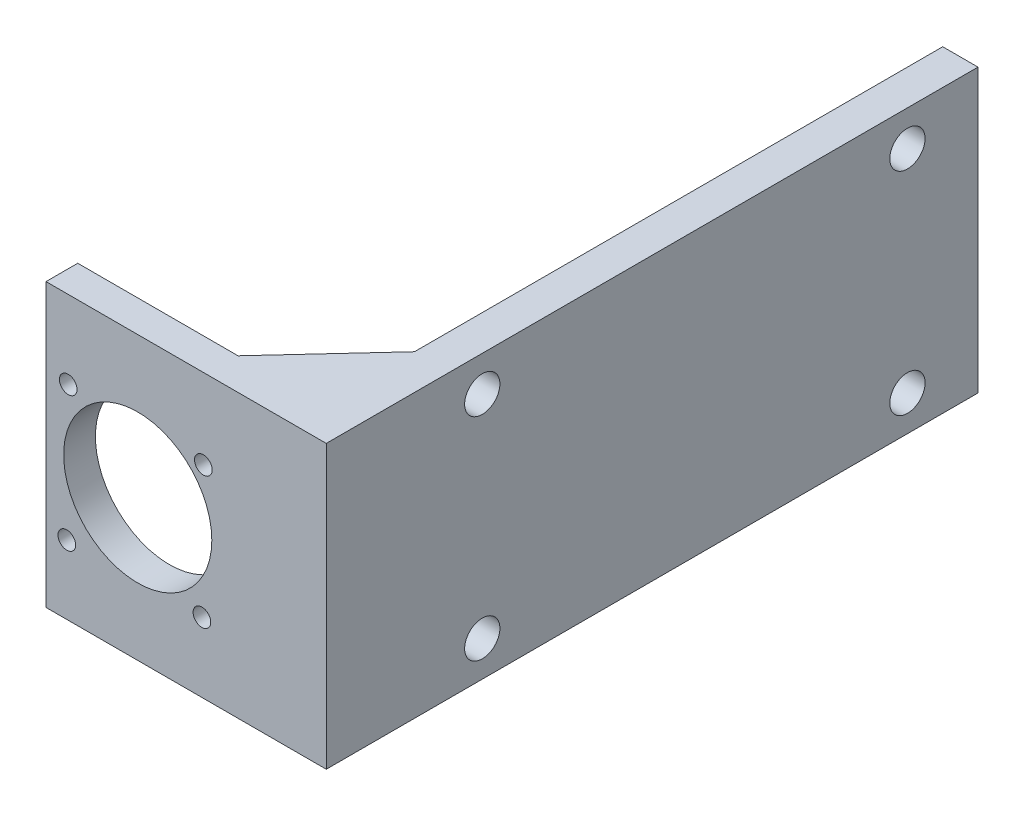
from build123d import *

# Parameters (mm, degrees)
SKETCH1_R           = 10.5
SKETCH1_R_2         = 1.25
BOSS_EXTRUDE1_DEPTH = 4.5
SKETCH2_W           = 5
SKETCH2_H           = 40
BOSS_EXTRUDE2_DEPTH = 87.869807
SKETCH3_R           = 2.5
CUT_EXTRUDE1_DEPTH  = 6
BOSS_EXTRUDE3_DEPTH = 20
SKETCH5_W           = 12
SKETCH5_H           = 34
CUT_EXTRUDE2_DEPTH  = 87.869807
FILLET1_R           = 5


with BuildPart() as part:
    # Sketch1 → Boss-Extrude1 (new body)
    with BuildSketch(Plane.XY):
        Polygon((-26, -6), (0, -6), (13.72, -6), (13.72, 34), (0, 34), (-26, 34), align=None)
        with Locations((-13, 14)):
            Circle(SKETCH1_R, mode=Mode.SUBTRACT)
        with Locations((-3.9, 3.85)):
            Circle(SKETCH1_R_2, mode=Mode.SUBTRACT)
        with Locations((-23.05, 3.75)):
            Circle(SKETCH1_R_2, mode=Mode.SUBTRACT)
        with Locations((-22.85, 22.95)):
            Circle(SKETCH1_R_2, mode=Mode.SUBTRACT)
        with Locations((-3.7, 22.65)):
            Circle(SKETCH1_R_2, mode=Mode.SUBTRACT)
    extrude(amount=BOSS_EXTRUDE1_DEPTH)

    # Sketch2 → Boss-Extrude2 (add)
    with BuildSketch(Plane(origin=(0, 0, 0), x_dir=(-1, 0, 0), z_dir=(0, 0, -1))):
        with Locations((-11.22, 14)):
            Rectangle(SKETCH2_W, SKETCH2_H)
    extrude(amount=BOSS_EXTRUDE2_DEPTH)

    # Sketch3 → Cut-Extrude1 (cut, through all)
    with BuildSketch(Plane.ZY.offset(-8.72)):
        with Locations((-77.869807398, 29)):
            Circle(SKETCH3_R)
        with Locations((-77.869807398, -1)):
            Circle(SKETCH3_R)
        with Locations((-17.609807398, -1)):
            Circle(SKETCH3_R)
        with Locations((-17.609807398, 29)):
            Circle(SKETCH3_R)
    extrude(amount=-CUT_EXTRUDE1_DEPTH, mode=Mode.SUBTRACT)

    # Sketch4 → Boss-Extrude3 (add, symmetric)
    with BuildSketch(Plane(origin=(0, 14, 0), x_dir=(1, 0, 0), z_dir=(0, 1, 0))):
        Polygon((8.72, 13), (-3.28, 0), (8.72, 0), align=None)
    extrude(amount=BOSS_EXTRUDE3_DEPTH, both=True)

    # Sketch5 → Cut-Extrude2 (cut)
    with BuildSketch(Plane(origin=(0, 0, 0), x_dir=(-1, 0, 0), z_dir=(0, 0, -1))):
        with Locations((-2.72, 14)):
            Rectangle(SKETCH5_W, SKETCH5_H)
    extrude(amount=CUT_EXTRUDE2_DEPTH, mode=Mode.SUBTRACT)

    # Fillet1
    fillet1_edges = [part.edges().sort_by_distance(p)[0] for p in [
        (8.72, 14, 0),
    ]]
    fillet(fillet1_edges, radius=FILLET1_R)


solid = part.part
